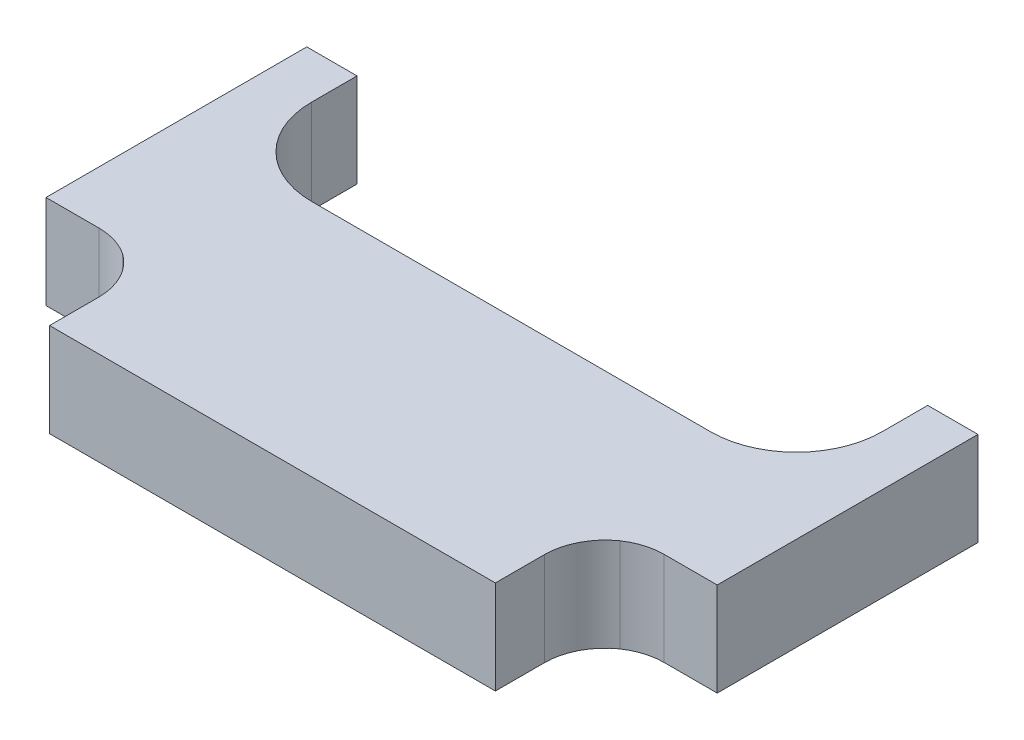
from build123d import *

# Parameters (mm, degrees)
BOSS_EXTRUDE1_DEPTH = 1.5


with BuildPart() as part:
    # Sketch3 → Boss-Extrude1 (new body, symmetric)
    with BuildSketch(Plane(origin=(0, 0, 0), x_dir=(1, 0, 0), z_dir=(0, 1, 0))):
        with BuildLine():
            Line((6.39, 1.715), (-6.39, 1.715))
            ThreePointArc((-6.39, 1.715), (-8.334543648, 2.520456352), (-9.14, 4.465))
            Line((-9.14, 4.465), (-9.14, 5.925))
            Line((-9.14, 5.925), (-10.75, 5.925))
            Line((-10.75, 5.925), (-10.75, -2.428885313))
            Line((-10.75, -2.428885313), (-9.053324958, -2.428885313))
            ThreePointArc((-9.053324958, -2.428885313), (-8.483744199, -2.513924788), (-7.963842259, -2.761626073))
            ThreePointArc((-7.963842259, -2.761626073), (-7.358164616, -3.457324711), (-7.14, -4.353564747))
            Line((-7.14, -4.353564747), (-7.14, -5.925))
            Line((-7.14, -5.925), (7.14, -5.925))
            Line((7.14, -5.925), (7.14, -4.353564747))
            ThreePointArc((7.14, -4.353564747), (7.358164616, -3.457324711), (7.963842259, -2.761626073))
            ThreePointArc((7.963842259, -2.761626073), (8.483744199, -2.513924788), (9.053324958, -2.428885313))
            Line((9.053324958, -2.428885313), (10.75, -2.428885313))
            Line((10.75, -2.428885313), (10.75, 5.925))
            Line((10.75, 5.925), (9.14, 5.925))
            Line((9.14, 5.925), (9.14, 4.465))
            ThreePointArc((9.14, 4.465), (8.334543648, 2.520456352), (6.39, 1.715))
        make_face()
    extrude(amount=BOSS_EXTRUDE1_DEPTH, both=True)


solid = part.part
